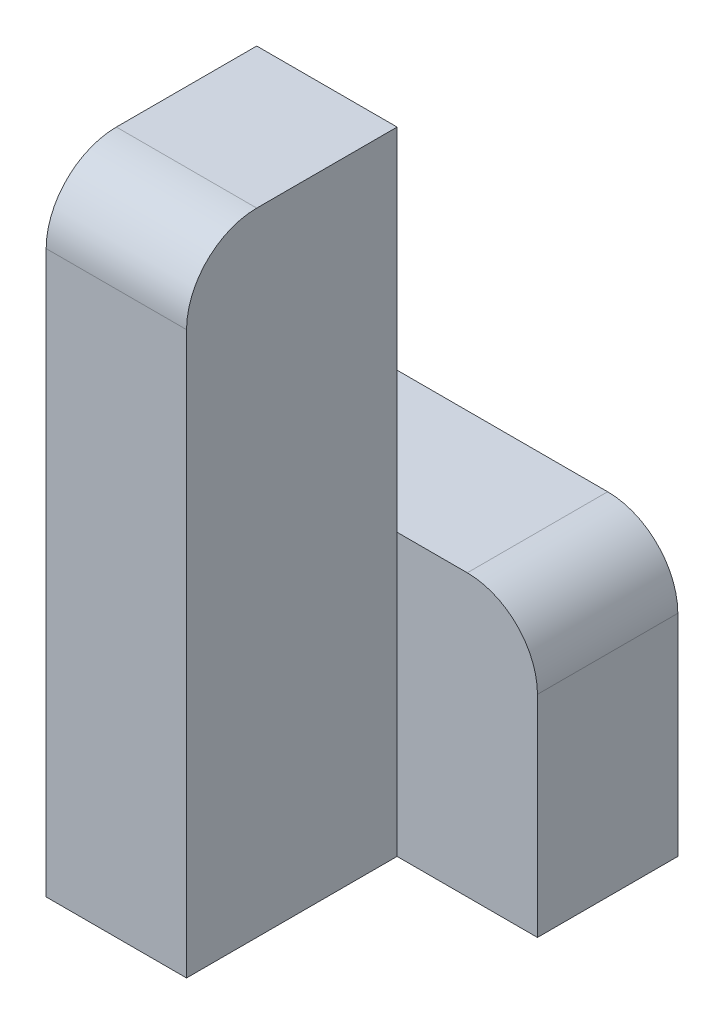
from build123d import *

# Parameters (mm, degrees)
SKETCH1_W           = 20
SKETCH1_H           = 90
BOSS_EXTRUDE1_DEPTH = 30
SKETCH2_W           = 40
SKETCH2_H           = 40
BOSS_EXTRUDE2_DEPTH = 20
FILLET1_R           = 10


with BuildPart() as part:
    # Sketch1 → Boss-Extrude1 (new body)
    with BuildSketch(Plane.XY):
        with Locations((-20, -45)):
            Rectangle(SKETCH1_W, SKETCH1_H)
    extrude(amount=BOSS_EXTRUDE1_DEPTH)

    # Sketch2 → Boss-Extrude2 (add)
    with BuildSketch(Plane.XY):
        with Locations((-10, -70)):
            Rectangle(SKETCH2_W, SKETCH2_H)
    extrude(amount=-BOSS_EXTRUDE2_DEPTH)

    # Fillet1
    fillet1_edges = [part.edges().sort_by_distance(p)[0] for p in [
        (10, -50, -10),
        (-20, 0, 30),
    ]]
    fillet(fillet1_edges, radius=FILLET1_R)


solid = part.part
